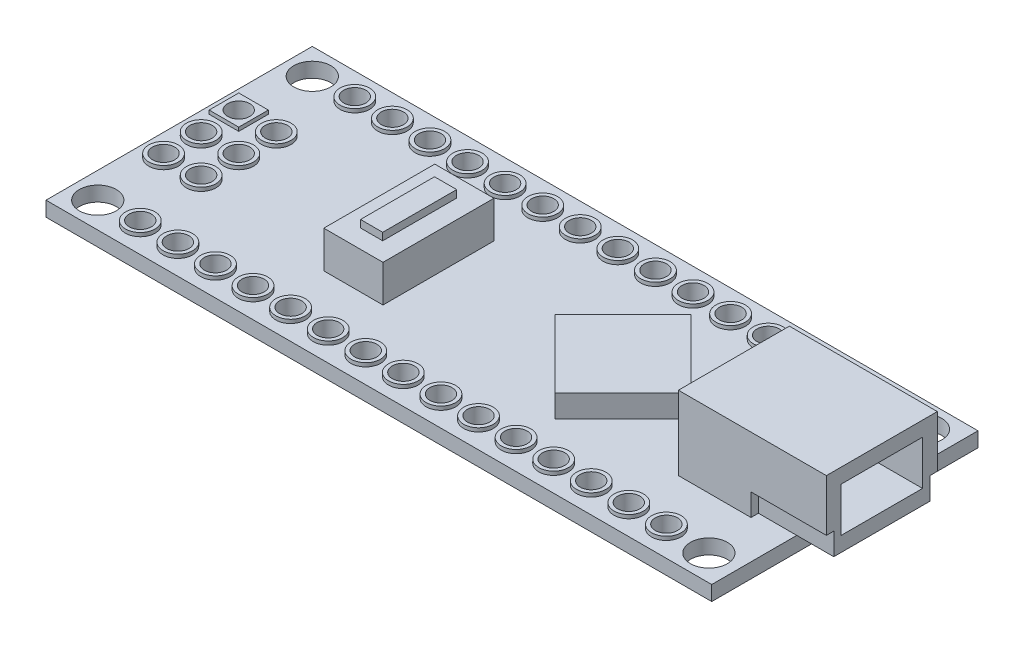
from build123d import *

# Parameters (mm, degrees)
SKETCH1_W               = 45
SKETCH1_H               = 18
SKETCH1_R               = 1.25
SKETCH1_R_2             = 0.75
BOSS_EXTRUDE1_DEPTH     = 1
SKETCH2_W               = 10
SKETCH2_H               = 7.5
BOSS_EXTRUDE2_DEPTH     = 5
SKETCH4_W               = 5.5
SKETCH4_H               = 3
CUT_EXTRUDE1_DEPTH      = 1.094912365
CUT_EXTRUDE1_DEPTH_BACK = 7.5
SKETCH6_W               = 0.5
SKETCH6_H               = 1.5
CUT_EXTRUDE2_DEPTH      = 1.094912365
CUT_EXTRUDE2_DEPTH_BACK = 5
BOSS_EXTRUDE3_DEPTH     = 1.5
SKETCH8_W               = 4
SKETCH8_H               = 7.5
BOSS_EXTRUDE4_DEPTH     = 2.5
SKETCH9_W               = 1.5
SKETCH9_H               = 5
BOSS_EXTRUDE5_DEPTH     = 3
SKETCH10_R              = 0.75
CUT_EXTRUDE3_DEPTH      = 6
CUT_EXTRUDE3_DEPTH_BACK = 3.5
SKETCH11_R              = 1
SKETCH11_R_2            = 0.75
SKETCH11_W              = 2
SKETCH11_H              = 2
BOSS_EXTRUDE6_DEPTH     = 0.25


with BuildPart() as part:
    # Sketch1 → Boss-Extrude1 (new body)
    with BuildSketch(Plane(origin=(0, 0, 0), x_dir=(1, 0, 0), z_dir=(0, 1, 0))):
        with Locations((0.094912365, 0)):
            Rectangle(SKETCH1_W, SKETCH1_H)
        with Locations((-20.655087635, 7.25)):
            Circle(SKETCH1_R, mode=Mode.SUBTRACT)
        with Locations((20.655087635, 7.25)):
            Circle(SKETCH1_R, mode=Mode.SUBTRACT)
        with Locations((20.655087635, -7.25)):
            Circle(SKETCH1_R, mode=Mode.SUBTRACT)
        with Locations((-20.655087635, -7.25)):
            Circle(SKETCH1_R, mode=Mode.SUBTRACT)
        with Locations((-17.78086666, 7.25)):
            Circle(SKETCH1_R_2, mode=Mode.SUBTRACT)
        with Locations((-15.24086666, 7.25)):
            Circle(SKETCH1_R_2, mode=Mode.SUBTRACT)
        with Locations((-10.16086666, 7.25)):
            Circle(SKETCH1_R_2, mode=Mode.SUBTRACT)
        with Locations((-7.62086666, 7.25)):
            Circle(SKETCH1_R_2, mode=Mode.SUBTRACT)
        with Locations((-5.08086666, 7.25)):
            Circle(SKETCH1_R_2, mode=Mode.SUBTRACT)
        with Locations((-2.54086666, 7.25)):
            Circle(SKETCH1_R_2, mode=Mode.SUBTRACT)
        with Locations((-12.70086666, 7.25)):
            Circle(SKETCH1_R_2, mode=Mode.SUBTRACT)
        with Locations((-0.00086666, 7.25)):
            Circle(SKETCH1_R_2, mode=Mode.SUBTRACT)
        with Locations((2.54086666, 7.25)):
            Circle(SKETCH1_R_2, mode=Mode.SUBTRACT)
        with Locations((5.08086666, 7.25)):
            Circle(SKETCH1_R_2, mode=Mode.SUBTRACT)
        with Locations((7.62086666, 7.25)):
            Circle(SKETCH1_R_2, mode=Mode.SUBTRACT)
        with Locations((10.16086666, 7.25)):
            Circle(SKETCH1_R_2, mode=Mode.SUBTRACT)
        with Locations((12.70086666, 7.25)):
            Circle(SKETCH1_R_2, mode=Mode.SUBTRACT)
        with Locations((15.24086666, 7.25)):
            Circle(SKETCH1_R_2, mode=Mode.SUBTRACT)
        with Locations((17.78086666, 7.25)):
            Circle(SKETCH1_R_2, mode=Mode.SUBTRACT)
        with Locations((17.78086666, -7.25)):
            Circle(SKETCH1_R_2, mode=Mode.SUBTRACT)
        with Locations((15.24086666, -7.25)):
            Circle(SKETCH1_R_2, mode=Mode.SUBTRACT)
        with Locations((12.70086666, -7.25)):
            Circle(SKETCH1_R_2, mode=Mode.SUBTRACT)
        with Locations((10.16086666, -7.25)):
            Circle(SKETCH1_R_2, mode=Mode.SUBTRACT)
        with Locations((7.62086666, -7.25)):
            Circle(SKETCH1_R_2, mode=Mode.SUBTRACT)
        with Locations((5.08086666, -7.25)):
            Circle(SKETCH1_R_2, mode=Mode.SUBTRACT)
        with Locations((2.54086666, -7.25)):
            Circle(SKETCH1_R_2, mode=Mode.SUBTRACT)
        with Locations((-0.00086666, -7.25)):
            Circle(SKETCH1_R_2, mode=Mode.SUBTRACT)
        with Locations((-2.54086666, -7.25)):
            Circle(SKETCH1_R_2, mode=Mode.SUBTRACT)
        with Locations((-5.08086666, -7.25)):
            Circle(SKETCH1_R_2, mode=Mode.SUBTRACT)
        with Locations((-7.62086666, -7.25)):
            Circle(SKETCH1_R_2, mode=Mode.SUBTRACT)
        with Locations((-10.16086666, -7.25)):
            Circle(SKETCH1_R_2, mode=Mode.SUBTRACT)
        with Locations((-12.70086666, -7.25)):
            Circle(SKETCH1_R_2, mode=Mode.SUBTRACT)
        with Locations((-15.24086666, -7.25)):
            Circle(SKETCH1_R_2, mode=Mode.SUBTRACT)
        with Locations((-17.78086666, -7.25)):
            Circle(SKETCH1_R_2, mode=Mode.SUBTRACT)
    extrude(amount=-BOSS_EXTRUDE1_DEPTH)

    # Sketch8 → Boss-Extrude4 (add)
    with BuildSketch(Plane(origin=(0, 0, 0), x_dir=(1, 0, 0), z_dir=(0, 1, 0))):
        with Locations((-6.876589912, 0)):
            Rectangle(SKETCH8_W, SKETCH8_H)
    extrude(amount=BOSS_EXTRUDE4_DEPTH)

    # Sketch10 → Cut-Extrude3 (cut, two sides)
    with BuildSketch(Plane(origin=(0, 0, 0), x_dir=(1, 0, 0), z_dir=(0, 1, 0))) as cut_extrude3_sk:
        with Locations((-18.376589912, 0)):
            Circle(SKETCH10_R)
        with Locations((-18.376589912, 2.54)):
            Circle(SKETCH10_R)
        with Locations((-18.376589912, -2.54)):
            Circle(SKETCH10_R)
        with Locations((-20.916589912, 2.54)):
            Circle(SKETCH10_R)
        with Locations((-20.916589912, -2.54)):
            Circle(SKETCH10_R)
        with Locations((-20.916589912, 0)):
            Circle(SKETCH10_R)
    extrude(amount=CUT_EXTRUDE3_DEPTH, mode=Mode.SUBTRACT)
    extrude(cut_extrude3_sk.sketch, amount=-CUT_EXTRUDE3_DEPTH_BACK, mode=Mode.SUBTRACT)

    # Sketch11 → Boss-Extrude6 (add)
    with BuildSketch(Plane(origin=(0, 0, 0), x_dir=(1, 0, 0), z_dir=(0, 1, 0))):
        with Locations((-17.78086666, 7.25)):
            Circle(SKETCH11_R)
        with Locations((-17.78086666, 7.25)):
            Circle(SKETCH11_R_2, mode=Mode.SUBTRACT)
        with Locations((-15.24086666, 7.25)):
            Circle(SKETCH11_R)
        with Locations((-15.24086666, 7.25)):
            Circle(SKETCH11_R_2, mode=Mode.SUBTRACT)
        with Locations((-12.70086666, 7.25)):
            Circle(SKETCH11_R)
        with Locations((-12.70086666, 7.25)):
            Circle(SKETCH11_R_2, mode=Mode.SUBTRACT)
        with Locations((-10.16086666, 7.25)):
            Circle(SKETCH11_R)
        with Locations((-10.16086666, 7.25)):
            Circle(SKETCH11_R_2, mode=Mode.SUBTRACT)
        with Locations((-7.62086666, 7.25)):
            Circle(SKETCH11_R)
        with Locations((-7.62086666, 7.25)):
            Circle(SKETCH11_R_2, mode=Mode.SUBTRACT)
        with Locations((-5.08086666, 7.25)):
            Circle(SKETCH11_R)
        with Locations((-5.08086666, 7.25)):
            Circle(SKETCH11_R_2, mode=Mode.SUBTRACT)
        with Locations((-2.54086666, 7.25)):
            Circle(SKETCH11_R)
        with Locations((-2.54086666, 7.25)):
            Circle(SKETCH11_R_2, mode=Mode.SUBTRACT)
        with Locations((-0.00086666, 7.25)):
            Circle(SKETCH11_R)
        with Locations((-0.00086666, 7.25)):
            Circle(SKETCH11_R_2, mode=Mode.SUBTRACT)
        with Locations((2.54086666, 7.25)):
            Circle(SKETCH11_R)
        with Locations((2.54086666, 7.25)):
            Circle(SKETCH11_R_2, mode=Mode.SUBTRACT)
        with Locations((5.08086666, 7.25)):
            Circle(SKETCH11_R)
        with Locations((5.08086666, 7.25)):
            Circle(SKETCH11_R_2, mode=Mode.SUBTRACT)
        with Locations((7.62086666, 7.25)):
            Circle(SKETCH11_R)
        with Locations((7.62086666, 7.25)):
            Circle(SKETCH11_R_2, mode=Mode.SUBTRACT)
        with Locations((10.16086666, 7.25)):
            Circle(SKETCH11_R)
        with Locations((10.16086666, 7.25)):
            Circle(SKETCH11_R_2, mode=Mode.SUBTRACT)
        with Locations((12.70086666, 7.25)):
            Circle(SKETCH11_R)
        with Locations((12.70086666, 7.25)):
            Circle(SKETCH11_R_2, mode=Mode.SUBTRACT)
        with Locations((15.24086666, 7.25)):
            Circle(SKETCH11_R)
        with Locations((15.24086666, 7.25)):
            Circle(SKETCH11_R_2, mode=Mode.SUBTRACT)
        with Locations((17.78086666, 7.25)):
            Circle(SKETCH11_R)
        with Locations((17.78086666, 7.25)):
            Circle(SKETCH11_R_2, mode=Mode.SUBTRACT)
        with Locations((17.78086666, -7.25)):
            Circle(SKETCH11_R)
        with Locations((17.78086666, -7.25)):
            Circle(SKETCH11_R_2, mode=Mode.SUBTRACT)
        with Locations((15.24086666, -7.25)):
            Circle(SKETCH11_R)
        with Locations((15.24086666, -7.25)):
            Circle(SKETCH11_R_2, mode=Mode.SUBTRACT)
        with Locations((12.70086666, -7.25)):
            Circle(SKETCH11_R)
        with Locations((12.70086666, -7.25)):
            Circle(SKETCH11_R_2, mode=Mode.SUBTRACT)
        with Locations((10.16086666, -7.25)):
            Circle(SKETCH11_R)
        with Locations((10.16086666, -7.25)):
            Circle(SKETCH11_R_2, mode=Mode.SUBTRACT)
        with Locations((7.62086666, -7.25)):
            Circle(SKETCH11_R)
        with Locations((7.62086666, -7.25)):
            Circle(SKETCH11_R_2, mode=Mode.SUBTRACT)
        with Locations((5.08086666, -7.25)):
            Circle(SKETCH11_R)
        with Locations((5.08086666, -7.25)):
            Circle(SKETCH11_R_2, mode=Mode.SUBTRACT)
        with Locations((2.54086666, -7.25)):
            Circle(SKETCH11_R)
        with Locations((2.54086666, -7.25)):
            Circle(SKETCH11_R_2, mode=Mode.SUBTRACT)
        with Locations((-0.00086666, -7.25)):
            Circle(SKETCH11_R)
        with Locations((-0.00086666, -7.25)):
            Circle(SKETCH11_R_2, mode=Mode.SUBTRACT)
        with Locations((-2.54086666, -7.25)):
            Circle(SKETCH11_R)
        with Locations((-2.54086666, -7.25)):
            Circle(SKETCH11_R_2, mode=Mode.SUBTRACT)
        with Locations((-5.08086666, -7.25)):
            Circle(SKETCH11_R)
        with Locations((-5.08086666, -7.25)):
            Circle(SKETCH11_R_2, mode=Mode.SUBTRACT)
        with Locations((-7.62086666, -7.25)):
            Circle(SKETCH11_R)
        with Locations((-7.62086666, -7.25)):
            Circle(SKETCH11_R_2, mode=Mode.SUBTRACT)
        with Locations((-10.16086666, -7.25)):
            Circle(SKETCH11_R)
        with Locations((-10.16086666, -7.25)):
            Circle(SKETCH11_R_2, mode=Mode.SUBTRACT)
        with Locations((-12.70086666, -7.25)):
            Circle(SKETCH11_R)
        with Locations((-12.70086666, -7.25)):
            Circle(SKETCH11_R_2, mode=Mode.SUBTRACT)
        with Locations((-15.24086666, -7.25)):
            Circle(SKETCH11_R)
        with Locations((-15.24086666, -7.25)):
            Circle(SKETCH11_R_2, mode=Mode.SUBTRACT)
        with Locations((-17.78086666, -7.25)):
            Circle(SKETCH11_R)
        with Locations((-17.78086666, -7.25)):
            Circle(SKETCH11_R_2, mode=Mode.SUBTRACT)
        with Locations((-18.376589912, 2.54)):
            Circle(SKETCH11_R)
        with Locations((-18.376589912, 2.54)):
            Circle(SKETCH11_R_2, mode=Mode.SUBTRACT)
        with Locations((-18.376589912, 0)):
            Circle(SKETCH11_R)
        with Locations((-18.376589912, 0)):
            Circle(SKETCH11_R_2, mode=Mode.SUBTRACT)
        with Locations((-20.916589912, 0)):
            Circle(SKETCH11_R)
        with Locations((-20.916589912, 0)):
            Circle(SKETCH11_R_2, mode=Mode.SUBTRACT)
        with Locations((-20.916589912, -2.54)):
            Circle(SKETCH11_R)
        with Locations((-20.916589912, -2.54)):
            Circle(SKETCH11_R_2, mode=Mode.SUBTRACT)
        with Locations((-18.376589912, -2.54)):
            Circle(SKETCH11_R)
        with Locations((-18.376589912, -2.54)):
            Circle(SKETCH11_R_2, mode=Mode.SUBTRACT)
        with Locations((-20.916589912, 2.54)):
            Rectangle(SKETCH11_W, SKETCH11_H)
        with Locations((-20.916589912, 2.54)):
            Circle(SKETCH11_R_2, mode=Mode.SUBTRACT)
    extrude(amount=BOSS_EXTRUDE6_DEPTH)


with BuildPart() as body_2:
    # Sketch2 → Boss-Extrude2 (new body)
    with BuildSketch(Plane(origin=(0, 0, 0), x_dir=(1, 0, 0), z_dir=(0, 1, 0))):
        with Locations((20.094912365, 0)):
            Rectangle(SKETCH2_W, SKETCH2_H)
    extrude(amount=BOSS_EXTRUDE2_DEPTH)

    # Sketch4 → Cut-Extrude1 (cut, two sides)
    with BuildSketch(Plane(origin=(25, 0, 0), x_dir=(0, 0, -1), z_dir=(1, 0, 0))) as cut_extrude1_sk:
        with Locations((0, 2.5)):
            Rectangle(SKETCH4_W, SKETCH4_H)
    extrude(amount=CUT_EXTRUDE1_DEPTH, mode=Mode.SUBTRACT)
    extrude(cut_extrude1_sk.sketch, amount=-CUT_EXTRUDE1_DEPTH_BACK, mode=Mode.SUBTRACT)

    # Sketch6 → Cut-Extrude2 (cut, two sides)
    with BuildSketch(Plane(origin=(25, 0, 0), x_dir=(0, 0, -1), z_dir=(1, 0, 0))) as cut_extrude2_sk:
        with Locations((-3.5, 0.75)):
            Rectangle(SKETCH6_W, SKETCH6_H)
        with Locations((3.5, 0.75)):
            Rectangle(SKETCH6_W, SKETCH6_H)
    extrude(amount=CUT_EXTRUDE2_DEPTH, mode=Mode.SUBTRACT)
    extrude(cut_extrude2_sk.sketch, amount=-CUT_EXTRUDE2_DEPTH_BACK, mode=Mode.SUBTRACT)


with BuildPart() as body_3:
    # Sketch7 → Boss-Extrude3 (new body)
    with BuildSketch(Plane(origin=(0, 0, 0), x_dir=(1, 0, 0), z_dir=(0, 1, 0))):
        Polygon((7.594912365, 4.601513167), (2.993399199, 0), (7.594912365, -4.601513167), (12.196425532, 0), align=None)
    extrude(amount=BOSS_EXTRUDE3_DEPTH)


with BuildPart() as body_4:
    # Sketch9 → Boss-Extrude5 (new body)
    with BuildSketch(Plane(origin=(0, 0, 0), x_dir=(1, 0, 0), z_dir=(0, 1, 0))):
        with Locations((-6.894410923, 0)):
            Rectangle(SKETCH9_W, SKETCH9_H)
    extrude(amount=BOSS_EXTRUDE5_DEPTH)


solid = Compound([part.part, body_2.part, body_3.part, body_4.part])
